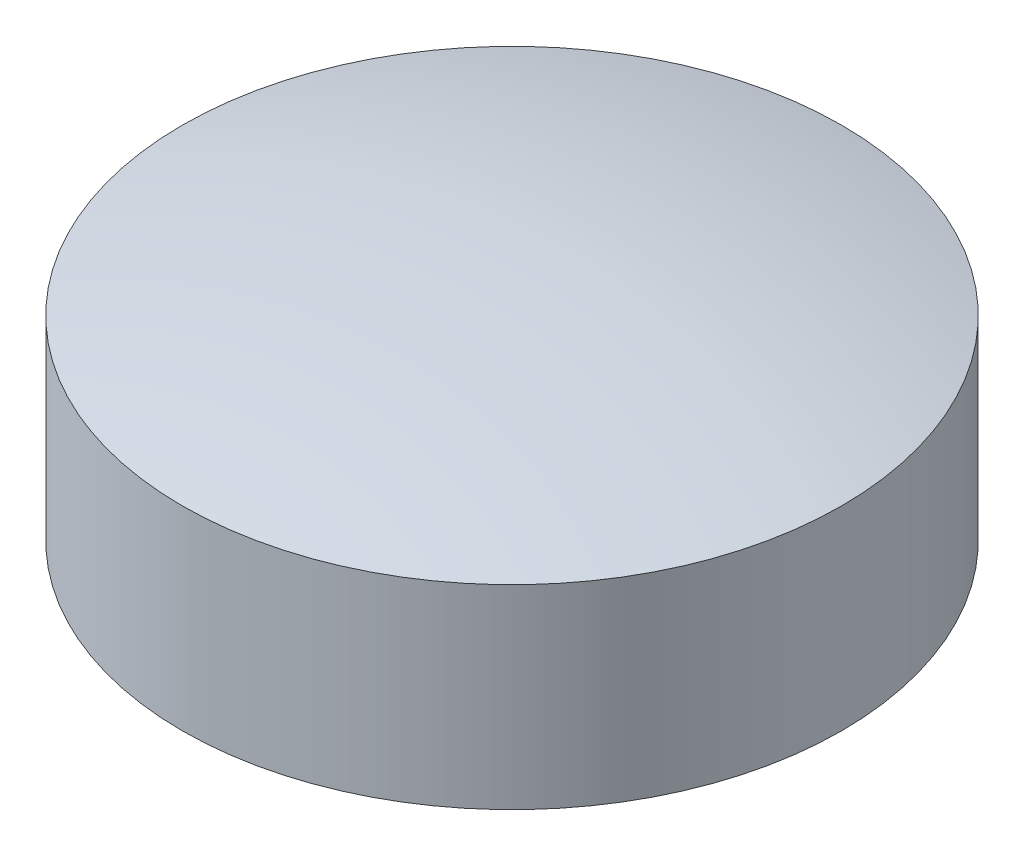
from build123d import *

# Parameters (mm, degrees)
SKETCH3_R          = 1.5
CUT_EXTRUDE1_DEPTH = 10


with BuildPart() as part:
    # Sketch2 → Revolve1 (revolve)
    with BuildSketch(Plane.XY):
        with BuildLine():
            Line((0, 0), (22, 0))
            Line((22, 0), (22, 13))
            ThreePointArc((22, 13), (11.101801656, 15.246545474), (0, 16))
            Line((0, 16), (0, 0))
        make_face()
    revolve(axis=Axis((0, 0, 0), (0, 1, 0)))

    # Sketch3 → Cut-Extrude1 (cut)
    with BuildSketch(Plane(origin=(0, 0, 0), x_dir=(1, 0, 0), z_dir=(0, 1, 0))):
        with Locations((-22, 0)):
            Circle(SKETCH3_R)
    extrude(amount=CUT_EXTRUDE1_DEPTH, mode=Mode.SUBTRACT)


solid = part.part
